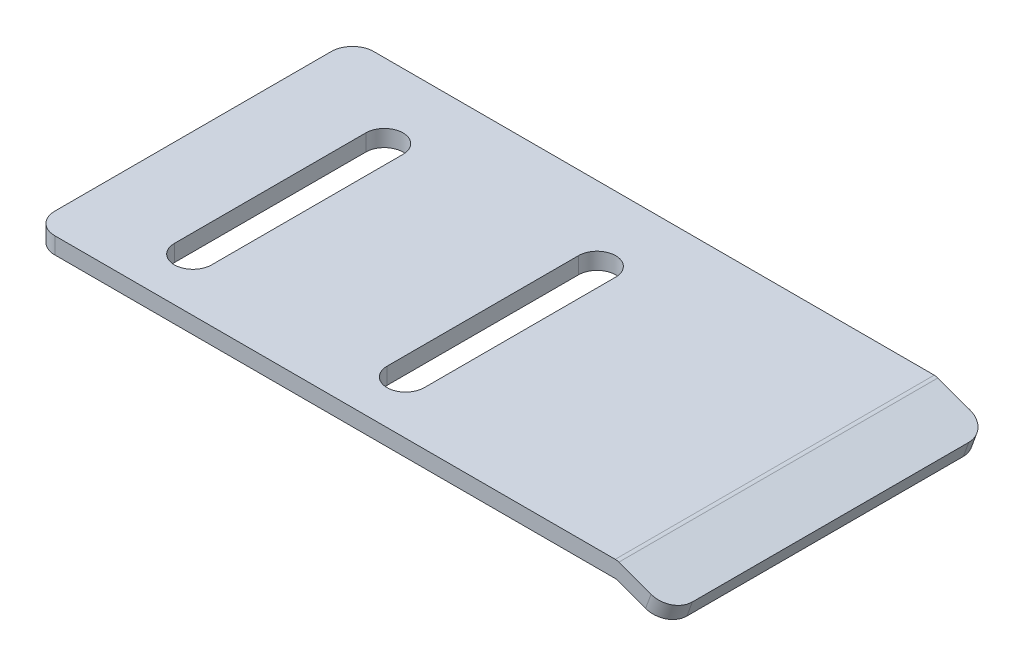
from build123d import *

# Parameters (mm, degrees)
BOSS_EXTRUDE1_DEPTH = 30
FILLET1_R           = 1
FILLET2_R           = 2
CUT_EXTRUDE1_DEPTH  = 4.256447705


with BuildPart() as part:
    # Sketch1 → Boss-Extrude1 (new body)
    with BuildSketch(Plane.XY):
        Polygon((-37.577345781, 8.579229267), (17.308314067, 8.579229267), (22.382654219, 6.732320493), (21.869624004, 5.322781562), (17.222654219, 7.014140243), (-37.577345781, 7.014140243), align=None)
    extrude(amount=BOSS_EXTRUDE1_DEPTH)

    # Fillet1
    fillet1_edges = [part.edges().sort_by_distance(p)[0] for p in [
        (17.308314067, 8.579229267, 15),
    ]]
    fillet(fillet1_edges, radius=FILLET1_R)

    # Fillet2
    fillet2_edges = [part.edges().sort_by_distance(p)[0] for p in [
        (22.126139112, 6.027551028, 30),
        (-37.577345781, 7.796684755, 30),
        (22.126139112, 6.027551028, 0),
        (-37.577345781, 7.796684755, 0),
    ]]
    fillet(fillet2_edges, radius=FILLET2_R)

    # Sketch3 → Cut-Extrude1 (cut, through all)
    with BuildSketch(Plane(origin=(0, 8.579229267, 0), x_dir=(1, 0, 0), z_dir=(0, 1, 0))):
        with BuildLine():
            Line((-25.827345781, -25), (-25.827345781, -7))
            ThreePointArc((-25.827345781, -7), (-27.577345781, -5.25), (-29.327345781, -7))
            Line((-29.327345781, -7), (-29.327345781, -25))
            ThreePointArc((-29.327345781, -25), (-27.577345781, -26.75), (-25.827345781, -25))
        make_face()
        with BuildLine():
            Line((-5.827345781, -25), (-5.827345781, -7))
            ThreePointArc((-5.827345781, -7), (-7.577345781, -5.25), (-9.327345781, -7))
            Line((-9.327345781, -7), (-9.327345781, -25))
            ThreePointArc((-9.327345781, -25), (-7.577345781, -26.75), (-5.827345781, -25))
        make_face()
    extrude(amount=-CUT_EXTRUDE1_DEPTH, mode=Mode.SUBTRACT)


solid = part.part
